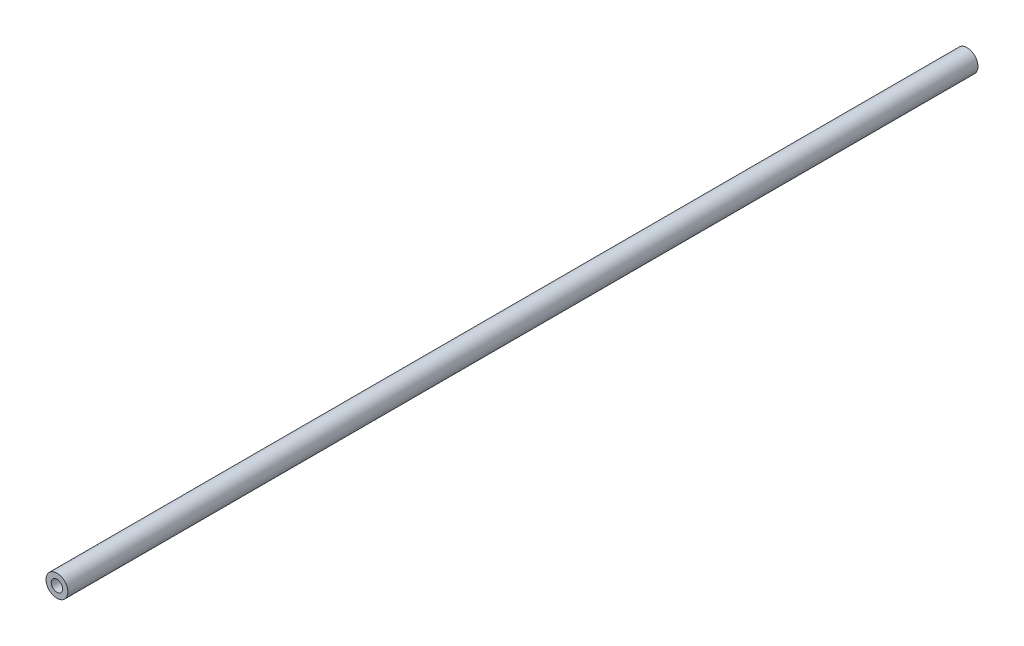
from build123d import *

# Parameters (mm, degrees)
SKETCH1_R           = 6.096
SKETCH1_R_2         = 3.175
BOSS_EXTRUDE1_DEPTH = 508


with BuildPart() as part:
    # Sketch1 → Boss-Extrude1 (new body)
    with BuildSketch(Plane.XY):
        Circle(SKETCH1_R)
        Circle(SKETCH1_R_2, mode=Mode.SUBTRACT)
    extrude(amount=BOSS_EXTRUDE1_DEPTH)


solid = part.part
